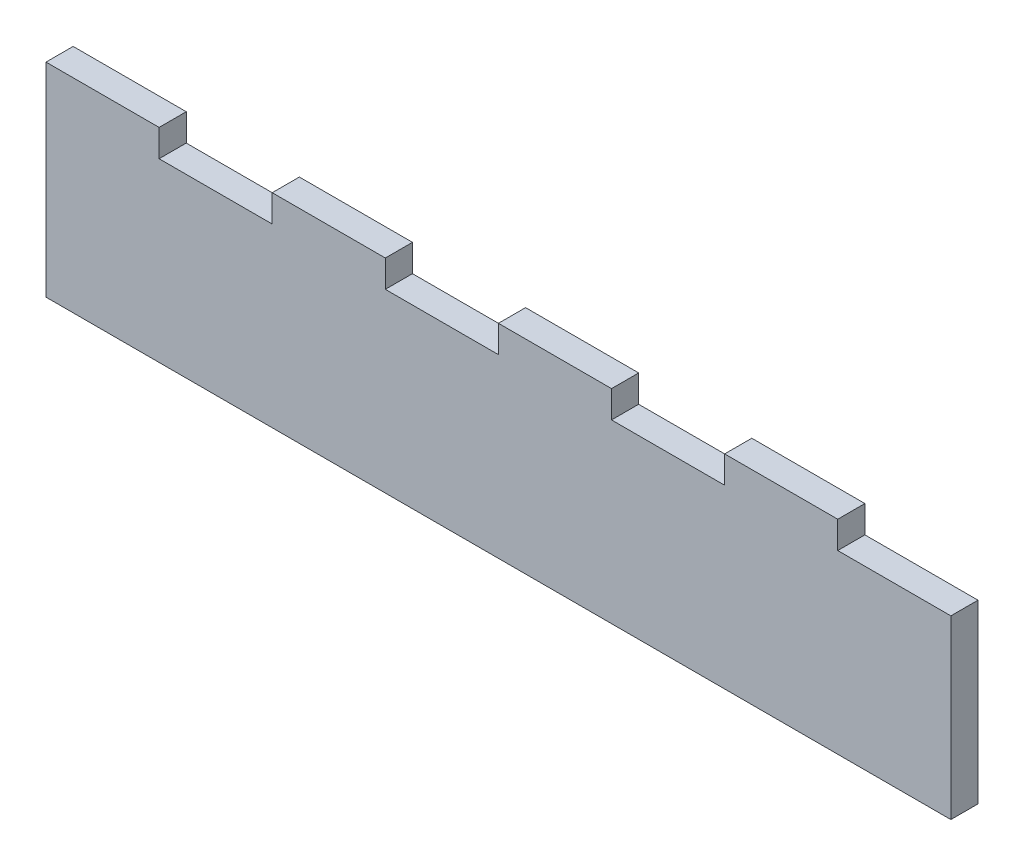
from build123d import *

# Parameters (mm, degrees)
RESSALTO_EXTRUS_O1_DEPTH = 6


with BuildPart() as part:
    # Esboço1 → Ressalto-extrusão1 (new body)
    with BuildSketch(Plane.XY):
        Polygon((50, 39), (50, 45), (75, 45), (75, 39), (100, 39), (100, 45), (125, 45), (125, 39), (150, 39), (150, 45), (175, 45), (175, 39), (200, 39), (200, 0), (0, 0), (0, 39), (0, 45), (25, 45), (25, 39), align=None)
    extrude(amount=RESSALTO_EXTRUS_O1_DEPTH)


solid = part.part
